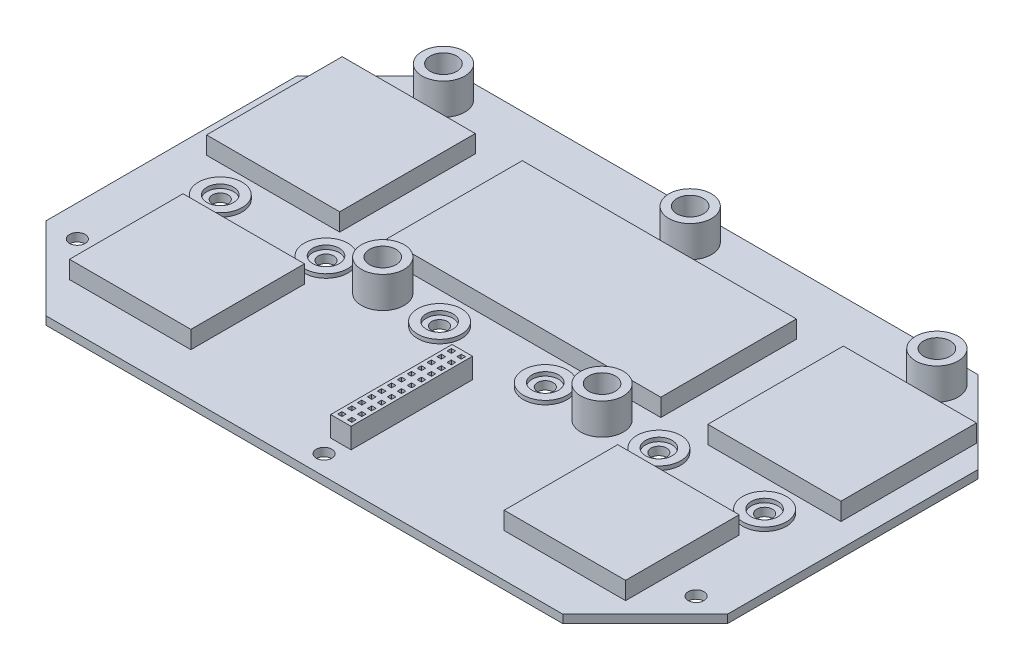
from build123d import *

# Parameters (mm, degrees)
EXTRUDE_1_DEPTH     = 2.1
SKETCH_2_R          = 2
CUT_EXTRUDE_1_DEPTH = 102.894111704
SKETCH_3_R          = 5.45
SKETCH_3_R_2        = 3.4
EXTRUDE_2_DEPTH     = 8
EXTRUDE_2_2_DEPTH   = 8
EXTRUDE_2_3_DEPTH   = 8
EXTRUDE_2_4_DEPTH   = 8
EXTRUDE_2_5_DEPTH   = 8
SKETCH_3_3_R        = 5.6
SKETCH_3_3_R_2      = 3.4
EXTRUDE_3_DEPTH     = 1
EXTRUDE_3_2_DEPTH   = 1
EXTRUDE_3_3_DEPTH   = 1
EXTRUDE_3_4_DEPTH   = 1
EXTRUDE_3_5_DEPTH   = 1
EXTRUDE_3_6_DEPTH   = 1
SKETCH_4_W          = 34
SKETCH_4_H          = 34.620012739
SKETCH_4_W_2        = 70
SKETCH_4_W_3        = 31
SKETCH_4_H_2        = 29
EXTRUDE_5_DEPTH     = 4.5
SKETCH_5_W          = 5.21
SKETCH_5_H          = 31
EXTRUDE_6_DEPTH     = 5.21
SKETCH_6_W          = 1.1
SKETCH_6_H          = 1.1
CUT_EXTRUDE_2_DEPTH = 2


with BuildPart() as part:
    # 草图1 → 凸台-拉伸1 (new body)
    with BuildSketch(Plane(origin=(0, 0, 0), x_dir=(1, 0, 0), z_dir=(0, 1, 0))):
        Polygon((-66, 53), (-87, 32), (-87, -32), (-66, -53), (66, -53), (87, -32), (87, 32), (66, 53), align=None)
    extrude(amount=EXTRUDE_1_DEPTH)

    # 草图2 → 切除-拉伸1 (cut, through all)
    with BuildSketch(Plane(origin=(0, 2.1, 0), x_dir=(1, 0, 0), z_dir=(0, 1, 0))):
        with Locations((0, 45.5)):
            Circle(SKETCH_2_R)
        with Locations((63, 45.5)):
            Circle(SKETCH_2_R)
        with Locations((-63, 45.5)):
            Circle(SKETCH_2_R)
        with Locations((-69.5, -5)):
            Circle(SKETCH_2_R)
        with Locations((-42.5, -5)):
            Circle(SKETCH_2_R)
        with Locations((-28, -5)):
            Circle(SKETCH_2_R)
        with Locations((-13.5, -5)):
            Circle(SKETCH_2_R)
        with Locations((13.5, -5)):
            Circle(SKETCH_2_R)
        with Locations((28, -5)):
            Circle(SKETCH_2_R)
        with Locations((42.5, -5)):
            Circle(SKETCH_2_R)
        with Locations((69.5, -5)):
            Circle(SKETCH_2_R)
        with Locations((79, -32)):
            Circle(SKETCH_2_R)
        with Locations((-79, -32)):
            Circle(SKETCH_2_R)
        with Locations((0, -48)):
            Circle(SKETCH_2_R)
    extrude(amount=-CUT_EXTRUDE_1_DEPTH, mode=Mode.SUBTRACT)

    # 草图4 → 凸台-拉伸5 (add)
    with BuildSketch(Plane(origin=(0, 2.1, 0), x_dir=(1, 0, 0), z_dir=(0, 1, 0))):
        with Locations((-64, 20.31000637)):
            Rectangle(SKETCH_4_W, SKETCH_4_H)
        with Locations((0, 20.31000637)):
            Rectangle(SKETCH_4_W_2, SKETCH_4_H)
        with Locations((64, 20.31000637)):
            Rectangle(SKETCH_4_W, SKETCH_4_H)
        with Locations((-55.5, -27.5)):
            Rectangle(SKETCH_4_W_3, SKETCH_4_H_2)
        with Locations((55.5, -27.5)):
            Rectangle(SKETCH_4_W_3, SKETCH_4_H_2)
    extrude(amount=EXTRUDE_5_DEPTH)

    # 草图5 → 凸台-拉伸6 (add)
    with BuildSketch(Plane(origin=(0, 2.1, 0), x_dir=(1, 0, 0), z_dir=(0, 1, 0))):
        with Locations((0, -28.2)):
            Rectangle(SKETCH_5_W, SKETCH_5_H)
    extrude(amount=EXTRUDE_6_DEPTH)

    # 草图6 → 切除-拉伸2 (cut)
    with BuildSketch(Plane(origin=(0, 7.31, 0), x_dir=(1, 0, 0), z_dir=(0, 1, 0))):
        with Locations((1.27, -42.17)):
            Rectangle(SKETCH_6_W, SKETCH_6_H)
        with Locations((-1.27, -42.17)):
            Rectangle(SKETCH_6_W, SKETCH_6_H)
        with Locations((1.27, -39.63)):
            Rectangle(SKETCH_6_W, SKETCH_6_H)
        with Locations((1.27, -37.09)):
            Rectangle(SKETCH_6_W, SKETCH_6_H)
        with Locations((1.27, -34.55)):
            Rectangle(SKETCH_6_W, SKETCH_6_H)
        with Locations((1.27, -32.01)):
            Rectangle(SKETCH_6_W, SKETCH_6_H)
        with Locations((1.27, -29.47)):
            Rectangle(SKETCH_6_W, SKETCH_6_H)
        with Locations((1.27, -26.93)):
            Rectangle(SKETCH_6_W, SKETCH_6_H)
        with Locations((1.27, -24.39)):
            Rectangle(SKETCH_6_W, SKETCH_6_H)
        with Locations((1.27, -21.85)):
            Rectangle(SKETCH_6_W, SKETCH_6_H)
        with Locations((1.27, -19.31)):
            Rectangle(SKETCH_6_W, SKETCH_6_H)
        with Locations((1.27, -16.77)):
            Rectangle(SKETCH_6_W, SKETCH_6_H)
        with Locations((1.27, -14.23)):
            Rectangle(SKETCH_6_W, SKETCH_6_H)
        with Locations((-1.27, -39.63)):
            Rectangle(SKETCH_6_W, SKETCH_6_H)
        with Locations((-1.27, -37.09)):
            Rectangle(SKETCH_6_W, SKETCH_6_H)
        with Locations((-1.27, -34.55)):
            Rectangle(SKETCH_6_W, SKETCH_6_H)
        with Locations((-1.27, -32.01)):
            Rectangle(SKETCH_6_W, SKETCH_6_H)
        with Locations((-1.27, -29.47)):
            Rectangle(SKETCH_6_W, SKETCH_6_H)
        with Locations((-1.27, -26.93)):
            Rectangle(SKETCH_6_W, SKETCH_6_H)
        with Locations((-1.27, -24.39)):
            Rectangle(SKETCH_6_W, SKETCH_6_H)
        with Locations((-1.27, -21.85)):
            Rectangle(SKETCH_6_W, SKETCH_6_H)
        with Locations((-1.27, -19.31)):
            Rectangle(SKETCH_6_W, SKETCH_6_H)
        with Locations((-1.27, -16.77)):
            Rectangle(SKETCH_6_W, SKETCH_6_H)
        with Locations((-1.27, -14.23)):
            Rectangle(SKETCH_6_W, SKETCH_6_H)
    extrude(amount=-CUT_EXTRUDE_2_DEPTH, mode=Mode.SUBTRACT)


with BuildPart() as body_2:
    # 草图3 → 凸台-拉伸2 (new body)
    with BuildSketch(Plane(origin=(0, 2.1, 0), x_dir=(1, 0, 0), z_dir=(0, 1, 0))):
        with Locations((-63, 45.5)):
            Circle(SKETCH_3_R)
        with Locations((-63, 45.5)):
            Circle(SKETCH_3_R_2, mode=Mode.SUBTRACT)
    extrude(amount=EXTRUDE_2_DEPTH)


with BuildPart() as body_3:
    # 草图3 → Extrude 2 2 (new body)
    with BuildSketch(Plane(origin=(0, 2.1, 0), x_dir=(1, 0, 0), z_dir=(0, 1, 0))):
        with Locations((0, 45.5)):
            Circle(SKETCH_3_R)
        with Locations((0, 45.5)):
            Circle(SKETCH_3_R_2, mode=Mode.SUBTRACT)
    extrude(amount=EXTRUDE_2_2_DEPTH)


with BuildPart() as body_4:
    # 草图3 → Extrude 2 3 (new body)
    with BuildSketch(Plane(origin=(0, 2.1, 0), x_dir=(1, 0, 0), z_dir=(0, 1, 0))):
        with Locations((63, 45.5)):
            Circle(SKETCH_3_R)
        with Locations((63, 45.5)):
            Circle(SKETCH_3_R_2, mode=Mode.SUBTRACT)
    extrude(amount=EXTRUDE_2_3_DEPTH)


with BuildPart() as body_5:
    # 草图3 → Extrude 2 4 (new body)
    with BuildSketch(Plane(origin=(0, 2.1, 0), x_dir=(1, 0, 0), z_dir=(0, 1, 0))):
        with Locations((-28, -5)):
            Circle(SKETCH_3_R)
        with Locations((-28, -5)):
            Circle(SKETCH_3_R_2, mode=Mode.SUBTRACT)
    extrude(amount=EXTRUDE_2_4_DEPTH)


with BuildPart() as body_6:
    # 草图3 → Extrude 2 5 (new body)
    with BuildSketch(Plane(origin=(0, 2.1, 0), x_dir=(1, 0, 0), z_dir=(0, 1, 0))):
        with Locations((28, -5)):
            Circle(SKETCH_3_R)
        with Locations((28, -5)):
            Circle(SKETCH_3_R_2, mode=Mode.SUBTRACT)
    extrude(amount=EXTRUDE_2_5_DEPTH)


with BuildPart() as body_7:
    # 草图3<3> → 凸台-拉伸3 (new body)
    with BuildSketch(Plane(origin=(0, 2.1, 0), x_dir=(1, 0, 0), z_dir=(0, 1, 0))):
        with Locations((-42.5, -5)):
            Circle(SKETCH_3_3_R)
        with Locations((-42.5, -5)):
            Circle(SKETCH_3_3_R_2, mode=Mode.SUBTRACT)
    extrude(amount=EXTRUDE_3_DEPTH)


with BuildPart() as body_8:
    # 草图3<3> → Extrude 3 2 (new body)
    with BuildSketch(Plane(origin=(0, 2.1, 0), x_dir=(1, 0, 0), z_dir=(0, 1, 0))):
        with Locations((-69.5, -5)):
            Circle(SKETCH_3_3_R)
        with Locations((-69.5, -5)):
            Circle(SKETCH_3_3_R_2, mode=Mode.SUBTRACT)
    extrude(amount=EXTRUDE_3_2_DEPTH)


with BuildPart() as body_9:
    # 草图3<3> → Extrude 3 3 (new body)
    with BuildSketch(Plane(origin=(0, 2.1, 0), x_dir=(1, 0, 0), z_dir=(0, 1, 0))):
        with Locations((-13.5, -5)):
            Circle(SKETCH_3_3_R)
        with Locations((-13.5, -5)):
            Circle(SKETCH_3_3_R_2, mode=Mode.SUBTRACT)
    extrude(amount=EXTRUDE_3_3_DEPTH)


with BuildPart() as body_10:
    # 草图3<3> → Extrude 3 4 (new body)
    with BuildSketch(Plane(origin=(0, 2.1, 0), x_dir=(1, 0, 0), z_dir=(0, 1, 0))):
        with Locations((13.5, -5)):
            Circle(SKETCH_3_3_R)
        with Locations((13.5, -5)):
            Circle(SKETCH_3_3_R_2, mode=Mode.SUBTRACT)
    extrude(amount=EXTRUDE_3_4_DEPTH)


with BuildPart() as body_11:
    # 草图3<3> → Extrude 3 5 (new body)
    with BuildSketch(Plane(origin=(0, 2.1, 0), x_dir=(1, 0, 0), z_dir=(0, 1, 0))):
        with Locations((42.5, -5)):
            Circle(SKETCH_3_3_R)
        with Locations((42.5, -5)):
            Circle(SKETCH_3_3_R_2, mode=Mode.SUBTRACT)
    extrude(amount=EXTRUDE_3_5_DEPTH)


with BuildPart() as body_12:
    # 草图3<3> → Extrude 3 6 (new body)
    with BuildSketch(Plane(origin=(0, 2.1, 0), x_dir=(1, 0, 0), z_dir=(0, 1, 0))):
        with Locations((69.5, -5)):
            Circle(SKETCH_3_3_R)
        with Locations((69.5, -5)):
            Circle(SKETCH_3_3_R_2, mode=Mode.SUBTRACT)
    extrude(amount=EXTRUDE_3_6_DEPTH)


solid = Compound([part.part, body_2.part, body_3.part, body_4.part, body_5.part, body_6.part, body_7.part, body_8.part, body_9.part, body_10.part, body_11.part, body_12.part])
